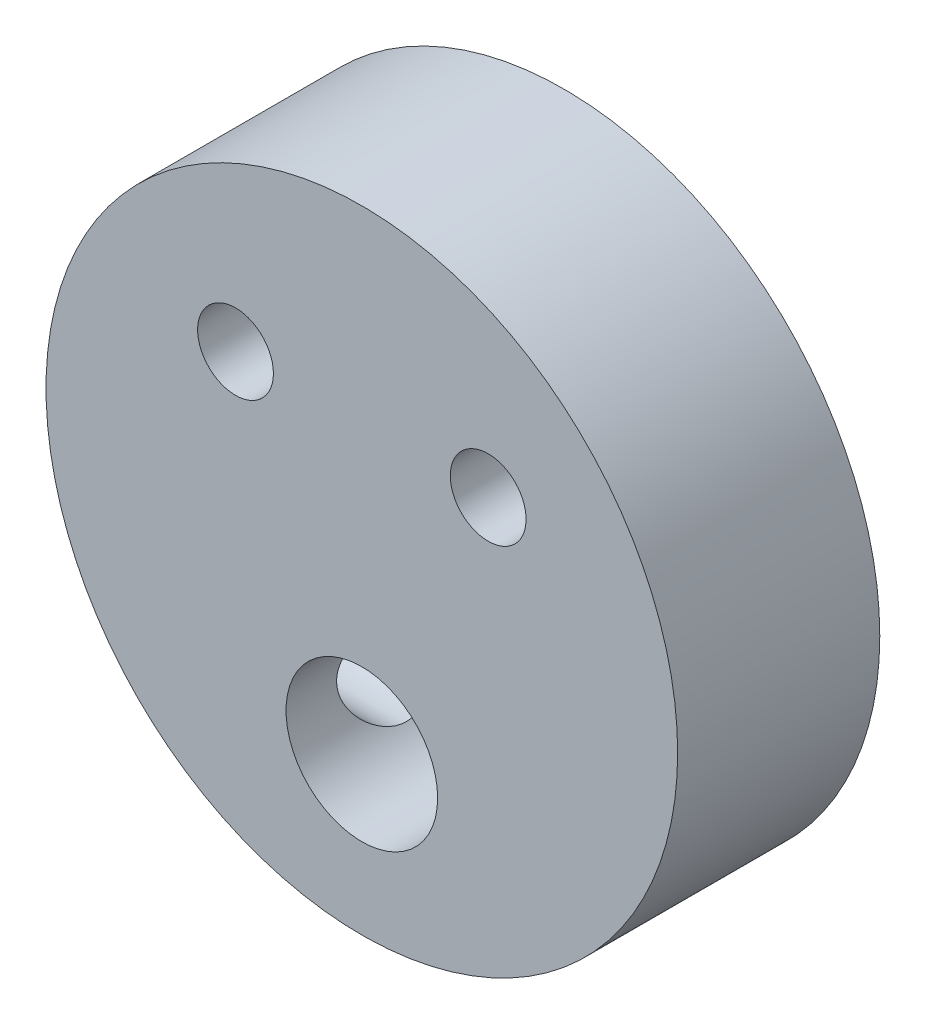
from build123d import *

# Parameters (mm, degrees)
SKETCH_1_R          = 12.5
SKETCH_1_R_2        = 3
EXTRUDE_1_DEPTH     = 8
SKETCH_2_R          = 2
CUT_EXTRUDE_1_DEPTH = 13.5
SKETCH_3_R          = 1.5
CUT_EXTRUDE_2_DEPTH = 9.0000001


with BuildPart() as part:
    # 草图1 → 凸台-拉伸1 (new body)
    with BuildSketch(Plane.XY):
        Circle(SKETCH_1_R)
        with Locations((0, -6.3)):
            Circle(SKETCH_1_R_2, mode=Mode.SUBTRACT)
    extrude(amount=EXTRUDE_1_DEPTH)

    # 草图2 → 切除-拉伸1 (cut, through all)
    with BuildSketch(Plane(origin=(0, 0, 0), x_dir=(0, 0, -1), z_dir=(1, 0, 0))):
        with Locations((-4, -6.3)):
            Circle(SKETCH_2_R)
    extrude(amount=-CUT_EXTRUDE_1_DEPTH, mode=Mode.SUBTRACT)

    # 草图3 → 切除-拉伸2 (cut, through all)
    with BuildSketch(Plane.XY.offset(8)):
        with Locations((-5, 5)):
            Circle(SKETCH_3_R)
        with Locations((5, 5)):
            Circle(SKETCH_3_R)
    extrude(amount=-CUT_EXTRUDE_2_DEPTH, mode=Mode.SUBTRACT)


solid = part.part
